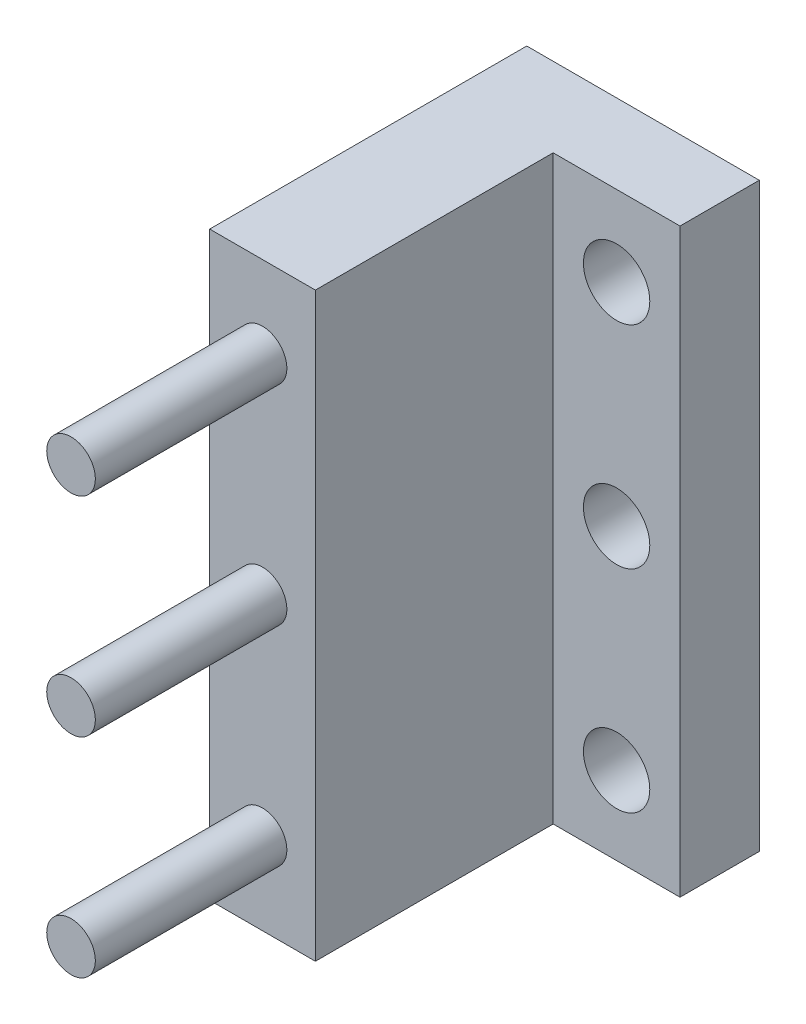
from build123d import *

# Parameters (mm, degrees)
SKETCH1_W           = 13.97
SKETCH1_H           = 34.925
BOSS_EXTRUDE1_DEPTH = 4.7625
SKETCH2_W           = 6.35
SKETCH2_H           = 34.925
BOSS_EXTRUDE2_DEPTH = 14.2875
SKETCH3_R           = 1.4605
BOSS_EXTRUDE3_DEPTH = 11.5062
SKETCH4_R           = 1.9939
CUT_EXTRUDE1_DEPTH  = 11.5062


with BuildPart() as part:
    # Sketch1 → Boss-Extrude1 (new body)
    with BuildSketch(Plane.XY.offset(25.4)):
        with Locations((-180.974999938, 108.007553269)):
            Rectangle(SKETCH1_W, SKETCH1_H)
    extrude(amount=BOSS_EXTRUDE1_DEPTH)

    # Sketch2 → Boss-Extrude2 (add)
    with BuildSketch(Plane.XY.offset(30.1625)):
        with Locations((-184.784999938, 108.007553269)):
            Rectangle(SKETCH2_W, SKETCH2_H)
    extrude(amount=BOSS_EXTRUDE2_DEPTH)

    # Sketch3 → Boss-Extrude3 (add)
    with BuildSketch(Plane.XY.offset(44.45)):
        with Locations((-184.784999938, 120.541132469)):
            Circle(SKETCH3_R)
        with Locations((-184.784999938, 108.007553269)):
            Circle(SKETCH3_R)
        with Locations((-184.784999938, 95.473974069)):
            Circle(SKETCH3_R)
    extrude(amount=BOSS_EXTRUDE3_DEPTH)

    # Sketch4 → Cut-Extrude1 (cut)
    with BuildSketch(Plane.XY.offset(30.1625)):
        with Locations((-177.799999938, 95.244053269)):
            Circle(SKETCH4_R)
        with Locations((-177.799999938, 107.944053269)):
            Circle(SKETCH4_R)
        with Locations((-177.799999938, 120.644053269)):
            Circle(SKETCH4_R)
    extrude(amount=-CUT_EXTRUDE1_DEPTH, mode=Mode.SUBTRACT)


solid = part.part
